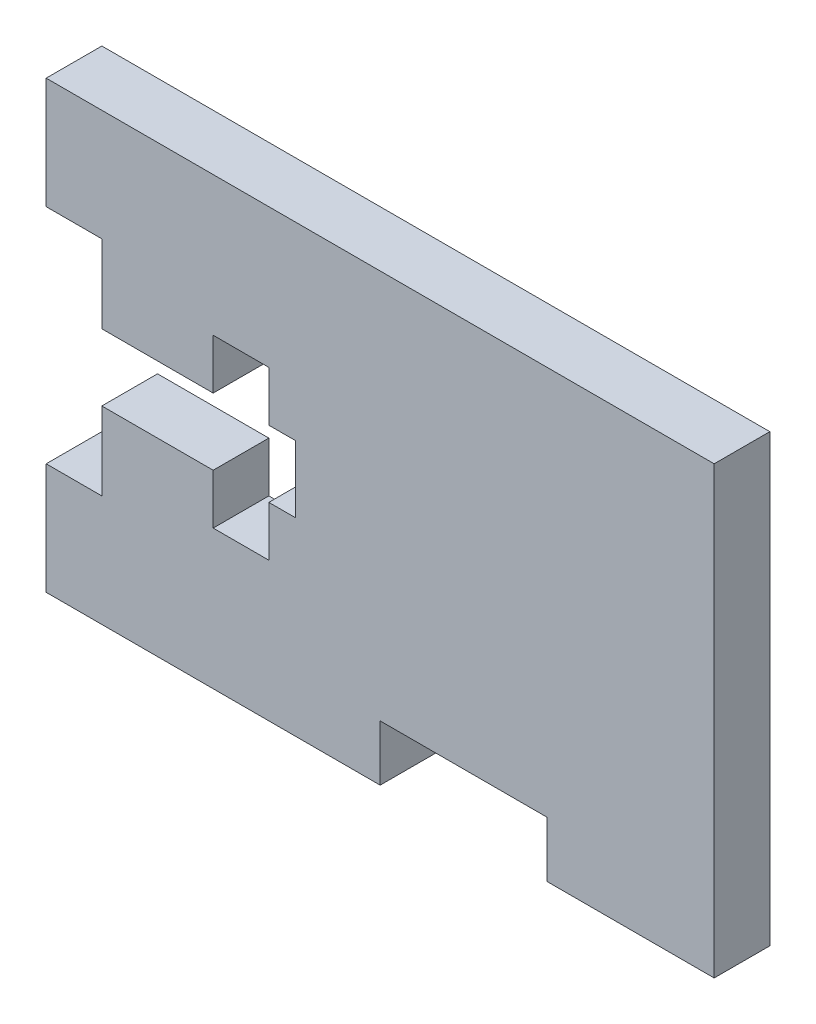
from build123d import *

# Parameters (mm, degrees)
BOSS_EXTRUDE1_DEPTH = 3.175


with BuildPart() as part:
    # Sketch1 → Boss-Extrude1 (new body)
    with BuildSketch(Plane.XY):
        Polygon((-19.05, 12.7), (19.05, 12.7), (19.05, -12.7), (9.525, -12.7), (9.525, -9.525), (0, -9.525), (0, -12.7), (-19.05, -12.7), (-19.05, -6.35), (-15.875, -6.35), (-15.875, -1.905), (-9.525, -1.905), (-9.525, -4.7625), (-6.35, -4.7625), (-6.35, -1.905), (-4.826, -1.905), (-4.826, 1.905), (-6.35, 1.905), (-6.35, 4.7625), (-9.525, 4.7625), (-9.525, 1.905), (-15.875, 1.905), (-15.875, 6.35), (-19.05, 6.35), align=None)
    extrude(amount=BOSS_EXTRUDE1_DEPTH)


solid = part.part
